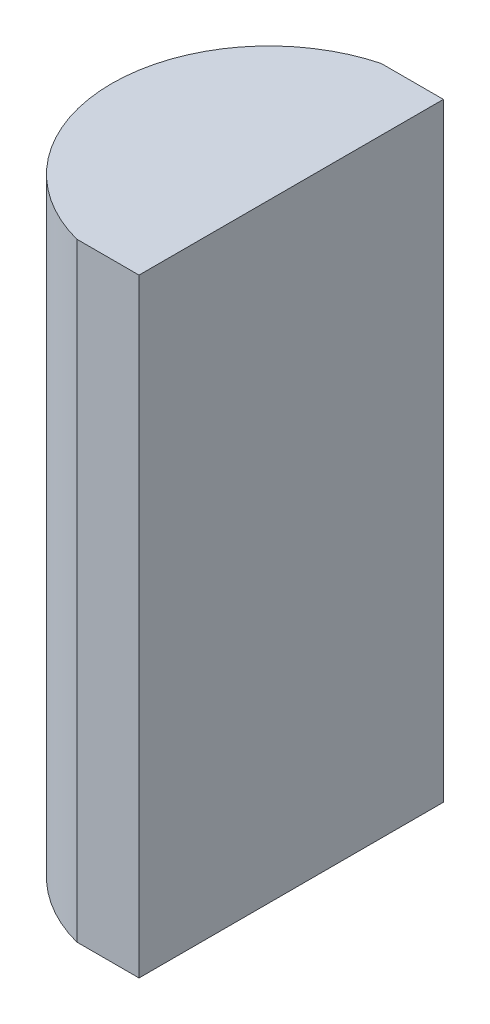
from build123d import *

# Parameters (mm, degrees)
EXTRUDE_1_DEPTH = 20


with BuildPart() as part:
    # 草图1 → 凸台-拉伸1 (new body)
    with BuildSketch(Plane(origin=(0, 0, 0), x_dir=(1, 0, 0), z_dir=(0, 1, 0))):
        with BuildLine():
            Line((3.040327915, 5), (5.085204335, 5))
            Line((5.085204335, 5), (5.085204335, -5))
            Line((5.085204335, -5), (3.040327915, -5))
            ThreePointArc((3.040327915, -5), (-0.814795665, 0), (3.040327915, 5))
        make_face()
    extrude(amount=EXTRUDE_1_DEPTH)


solid = part.part
